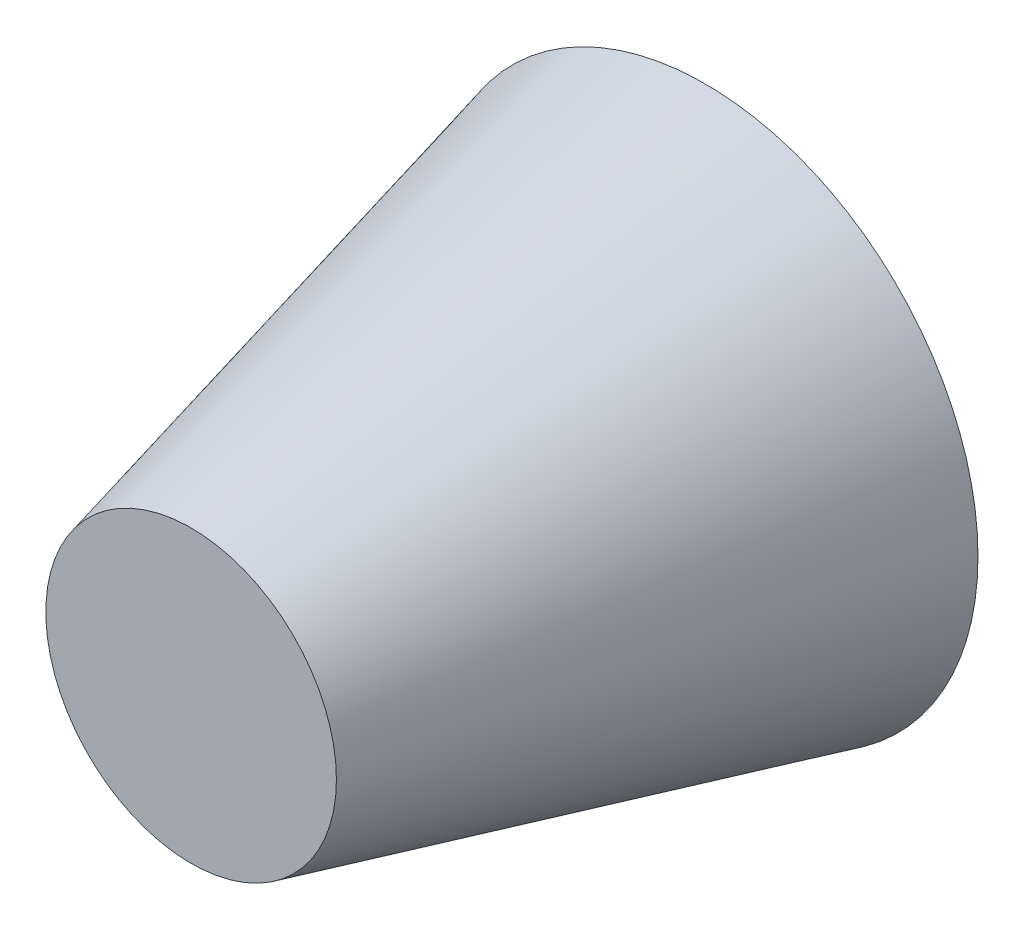
from build123d import *

# Parameters (mm, degrees)
SKETCH3_R = 3.25
SKETCH2_R = 6.1


with BuildPart() as part:
    # Sketch3 → Loft1 section 0
    with BuildSketch(Plane.XY.offset(11.5)):
        Circle(SKETCH3_R)
    # Sketch2 → Loft1 section 1
    with BuildSketch(Plane.XY):
        Circle(SKETCH2_R)
    loft()


solid = part.part
